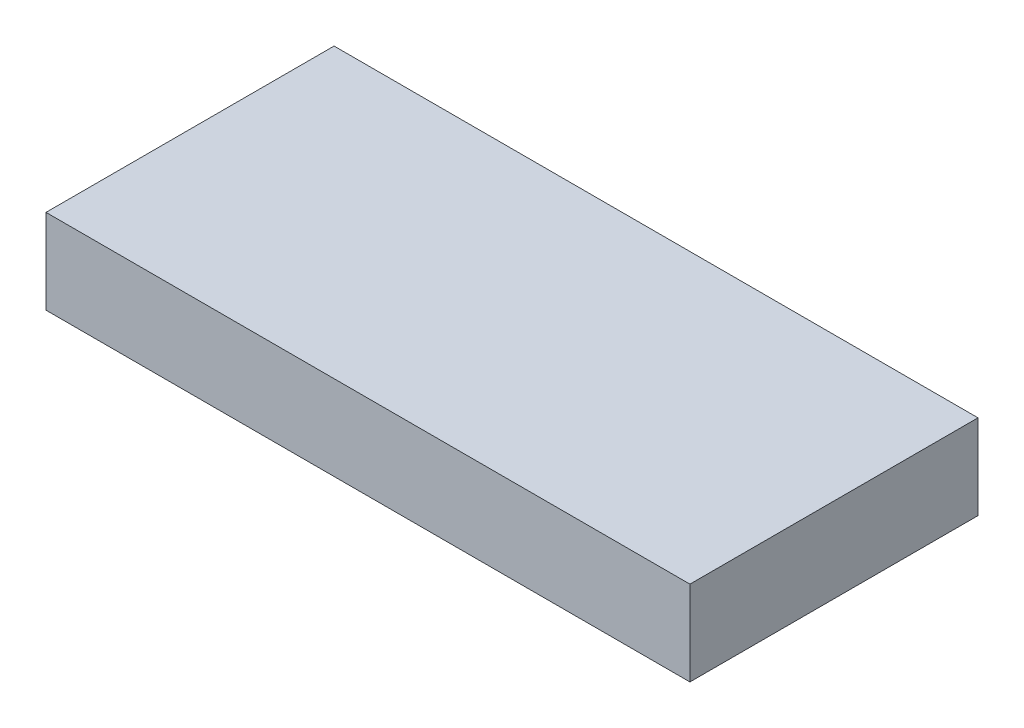
from build123d import *

# Parameters (mm, degrees)
SKETCH1_W           = 38
SKETCH1_H           = 17
BOSS_EXTRUDE1_DEPTH = 5


with BuildPart() as part:
    # Sketch1 → Boss-Extrude1 (new body)
    with BuildSketch(Plane(origin=(0, 0, 0), x_dir=(1, 0, 0), z_dir=(0, 1, 0))):
        Rectangle(SKETCH1_W, SKETCH1_H)
    extrude(amount=BOSS_EXTRUDE1_DEPTH)


solid = part.part
